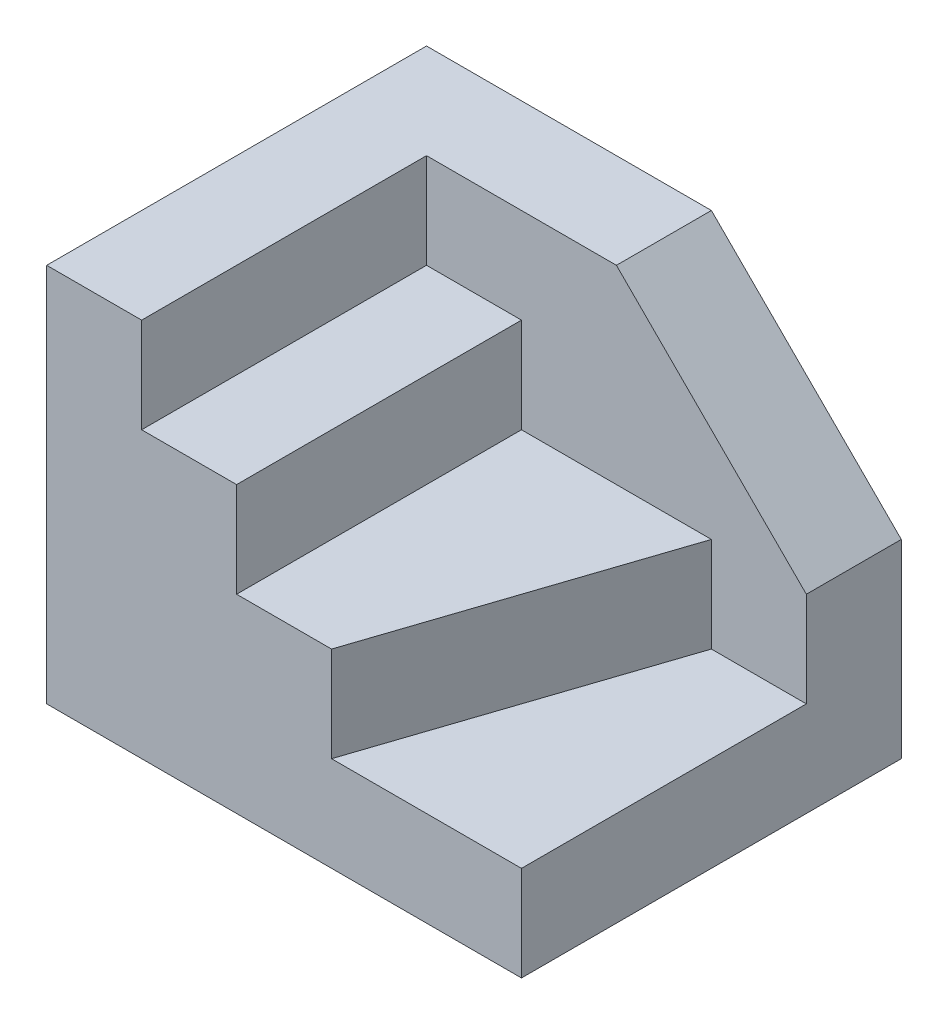
from build123d import *

# Parameters (mm, degrees)
BOSS_EXTRUDE1_DEPTH     = 40
SKETCH1_3_W             = 10
SKETCH1_3_H             = 30
BOSS_EXTRUDE2_DEPTH     = 30
BOSS_EXTRUDE3_DEPTH     = 20
BOSS_EXTRUDE4_DEPTH     = 10
CUT_EXTRUDE1_DEPTH      = 71.710678119
CUT_EXTRUDE1_DEPTH_BACK = 10


with BuildPart() as part:
    # Sketch1 → Boss-Extrude1 (new body)
    with BuildSketch(Plane(origin=(0, 0, 0), x_dir=(1, 0, 0), z_dir=(0, 1, 0))):
        Polygon((0, 40), (0, 0), (10, 0), (10, 30), (20, 30), (40, 30), (50, 30), (50, 40), align=None)
    extrude(amount=BOSS_EXTRUDE1_DEPTH)

    # Sketch1_3 → Boss-Extrude2 (add)
    with BuildSketch(Plane(origin=(0, 0, 0), x_dir=(1, 0, 0), z_dir=(0, 1, 0))):
        with Locations((15, 15)):
            Rectangle(SKETCH1_3_W, SKETCH1_3_H)
    extrude(amount=BOSS_EXTRUDE2_DEPTH)

    # Sketch1_4 → Boss-Extrude3 (add)
    with BuildSketch(Plane(origin=(0, 0, 0), x_dir=(1, 0, 0), z_dir=(0, 1, 0))):
        Polygon((20, 30), (20, 0), (30, 0), (40, 30), align=None)
    extrude(amount=BOSS_EXTRUDE3_DEPTH)

    # Sketch1_5 → Boss-Extrude4 (add)
    with BuildSketch(Plane(origin=(0, 0, 0), x_dir=(1, 0, 0), z_dir=(0, 1, 0))):
        Polygon((50, 0), (50, 30), (40, 30), (30, 0), align=None)
    extrude(amount=BOSS_EXTRUDE4_DEPTH)

    # Sketch2 → Cut-Extrude1 (cut, two sides: drawn at the far end of the back side and taken through both)
    with BuildSketch(Plane.XY.offset(-30).offset(-CUT_EXTRUDE1_DEPTH_BACK)):
        Polygon((-53.228798871, 123.228798871), (30, 40), (50, 20), (133.228798871, -63.228798871), (299.686396612, 103.228798871), (113.228798871, 289.686396612), align=None)
    extrude(amount=CUT_EXTRUDE1_DEPTH + CUT_EXTRUDE1_DEPTH_BACK, mode=Mode.SUBTRACT)


solid = part.part
